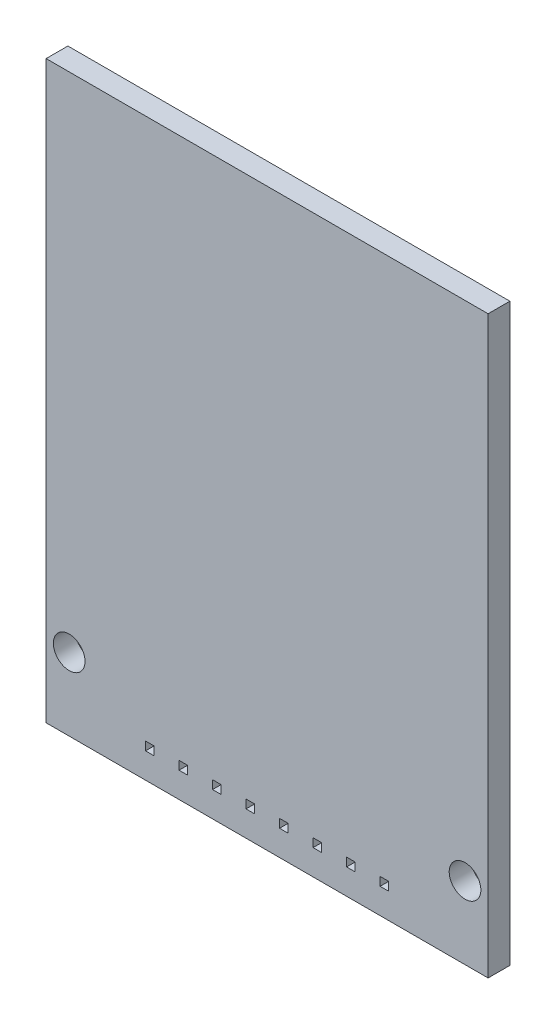
from build123d import *

# Parameters (mm, degrees)
SKETCH1_W               = 33.5
SKETCH1_H               = 43.6
BOSS_EXTRUDE1_DEPTH     = 1.65
BOSS_EXTRUDE2_START     = -3.05
SKETCH2_W               = 0.65
SKETCH2_H               = 0.65
BOSS_EXTRUDE2_DEPTH     = 11.55
CUT_EXTRUDE1_START      = -4.05
SKETCH2_2_W             = 0.65
SKETCH2_2_H             = 0.65
CUT_EXTRUDE1_DEPTH      = 13.55
LPATTERN1_COUNT         = 4
LPATTERN1_PITCH         = 2.54
MIRROR1_START           = -4.05
MIRROR1_COPY_1_SKETCH_W = 0.65
MIRROR1_COPY_1_SKETCH_H = 0.65
MIRROR1_COPY_1_DEPTH    = 13.55
MIRROR1_COPY_2_SKETCH_W = 0.65
MIRROR1_COPY_2_SKETCH_H = 0.65
MIRROR1_COPY_2_DEPTH    = 13.55
MIRROR1_COPY_3_SKETCH_W = 0.65
MIRROR1_COPY_3_SKETCH_H = 0.65
MIRROR1_COPY_3_DEPTH    = 13.55
MIRROR1_COPY_4_SKETCH_W = 0.65
MIRROR1_COPY_4_SKETCH_H = 0.65
MIRROR1_COPY_4_DEPTH    = 13.55
SKETCH3_R               = 1.2
CUT_EXTRUDE2_DEPTH      = 2.65


with BuildPart() as part:
    # Sketch1 → Boss-Extrude1 (new body)
    with BuildSketch(Plane.XY):
        Rectangle(SKETCH1_W, SKETCH1_H)
    extrude(amount=BOSS_EXTRUDE1_DEPTH)

    # Sketch2 → Boss-Extrude2 (add)
    with BuildSketch(Plane(origin=(0, 0, 0), x_dir=(-1, 0, 0), z_dir=(0, 0, -1)).offset(BOSS_EXTRUDE2_START)):
        with Locations((-1.27, -19.55)):
            Rectangle(SKETCH2_W, SKETCH2_H)
    boss_extrude2 = extrude(amount=BOSS_EXTRUDE2_DEPTH)

    # Sketch2_2 → Cut-Extrude1 (cut)
    with BuildSketch(Plane(origin=(0, 0, 0), x_dir=(-1, 0, 0), z_dir=(0, 0, -1)).offset(CUT_EXTRUDE1_START)):
        with Locations((-1.27, -19.55)):
            Rectangle(SKETCH2_2_W, SKETCH2_2_H)
    cut_extrude1 = extrude(amount=CUT_EXTRUDE1_DEPTH, mode=Mode.SUBTRACT)

    # LPattern1: Cut-Extrude1 ×4
    with Locations(*[(i * LPATTERN1_PITCH, 0, 0) for i in range(1, LPATTERN1_COUNT)]):
        add(cut_extrude1, mode=Mode.SUBTRACT)

    # Mirror1: Boss-Extrude2 across plane
    add(boss_extrude2.mirror(Plane(origin=(0, 0, 0), x_dir=(0, 0, 1), z_dir=(1, 0, 0))))

    # Mirror1 copy 1 sketch → Mirror1 copy 1 (cut)
    with BuildSketch(Plane(origin=(-2.54, 0, 0), x_dir=(1, 0, 0), z_dir=(0, 0, -1)).offset(MIRROR1_START)):
        with Locations((-1.27, 19.55)):
            Rectangle(MIRROR1_COPY_1_SKETCH_W, MIRROR1_COPY_1_SKETCH_H)
    extrude(amount=MIRROR1_COPY_1_DEPTH, mode=Mode.SUBTRACT)

    # Mirror1 copy 2 sketch → Mirror1 copy 2 (cut)
    with BuildSketch(Plane(origin=(-5.08, 0, 0), x_dir=(1, 0, 0), z_dir=(0, 0, -1)).offset(MIRROR1_START)):
        with Locations((-1.27, 19.55)):
            Rectangle(MIRROR1_COPY_2_SKETCH_W, MIRROR1_COPY_2_SKETCH_H)
    extrude(amount=MIRROR1_COPY_2_DEPTH, mode=Mode.SUBTRACT)

    # Mirror1 copy 3 sketch → Mirror1 copy 3 (cut)
    with BuildSketch(Plane(origin=(-7.62, 0, 0), x_dir=(1, 0, 0), z_dir=(0, 0, -1)).offset(MIRROR1_START)):
        with Locations((-1.27, 19.55)):
            Rectangle(MIRROR1_COPY_3_SKETCH_W, MIRROR1_COPY_3_SKETCH_H)
    extrude(amount=MIRROR1_COPY_3_DEPTH, mode=Mode.SUBTRACT)

    # Mirror1 copy 4 sketch → Mirror1 copy 4 (cut)
    with BuildSketch(Plane(origin=(0, 0, 0), x_dir=(1, 0, 0), z_dir=(0, 0, -1)).offset(MIRROR1_START)):
        with Locations((-1.27, 19.55)):
            Rectangle(MIRROR1_COPY_4_SKETCH_W, MIRROR1_COPY_4_SKETCH_H)
    extrude(amount=MIRROR1_COPY_4_DEPTH, mode=Mode.SUBTRACT)

    # Sketch3 → Cut-Extrude2 (cut, through all)
    with BuildSketch(Plane.XY):
        with Locations((-15, -16.3)):
            Circle(SKETCH3_R)
        with Locations((15, -16.3)):
            Circle(SKETCH3_R)
    extrude(amount=CUT_EXTRUDE2_DEPTH, mode=Mode.SUBTRACT)


solid = part.part
